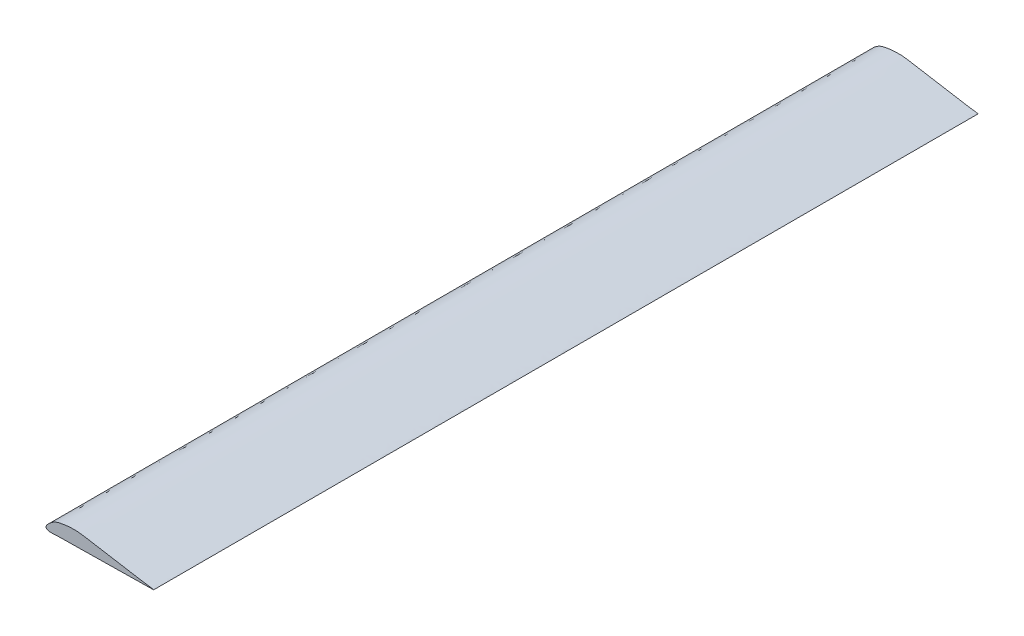
from build123d import *

# Parameters (mm, degrees)
BOSS_EXTRUDE1_DEPTH = 584.2


with BuildPart() as part:
    # Sketch1 → Boss-Extrude1 (new body)
    with BuildSketch(Plane.XY):
        with BuildLine():
            add(Edge.make_bspline(
                [(76.2, 0), (76.458583576, 0.180157567), (68.538144559, 1.173347983), (63.440040719, 2.154467745), (56.524538827, 3.271624756), (50.096082796, 4.353297253), (43.536851567, 5.44092215), (37.01366479, 6.540170394), (30.120458454, 7.64408335), (23.794576846, 8.868166839), (17.630857196, 8.938416345), (12.141450308, 8.304854483), (7.236430986, 7.315835475), (4.064200528, 5.376099052), (2.496868376, 4.040919544), (1.414706787, 2.937937429), (0.406658539, 1.896907645), (-0.434275958, 0.172470128), (0.819206142, -0.91445267), (3.34539384, -1.444033516), (7.363965762, -0.935694649), (12.646342403, -1.013380709), (17.945864405, -0.889048666), (23.24079995, -0.818846694), (28.536935845, -0.734142542), (33.832856916, -0.653317037), (39.128436264, -0.571433416), (44.425598035, -0.489949318), (49.716771836, -0.407925245), (55.030314391, -0.32761584), (60.260370564, -0.241033447), (65.802003395, -0.177828339), (70.180816081, -0.027387076), (75.993160033, -0.144107316), (76.2, 0)],
                knots=[0, 0, 0, 0, 0.042194185, 0.08438837, 0.126582556, 0.168776701, 0.210970886, 0.253165071, 0.295359257, 0.344459244, 0.376024875, 0.412649037, 0.45033922, 0.47015847, 0.482904042, 0.489771006, 0.499409248, 0.512015317, 0.51888228, 0.52748656, 0.56123752, 0.59498848, 0.62873944, 0.6624904, 0.69624136, 0.72999232, 0.76374328, 0.79749424, 0.8312452, 0.86499616, 0.89874712, 0.93249808, 0.96624904, 1, 1, 1, 1], degree=3))
        make_face()
    extrude(amount=BOSS_EXTRUDE1_DEPTH)


solid = part.part
